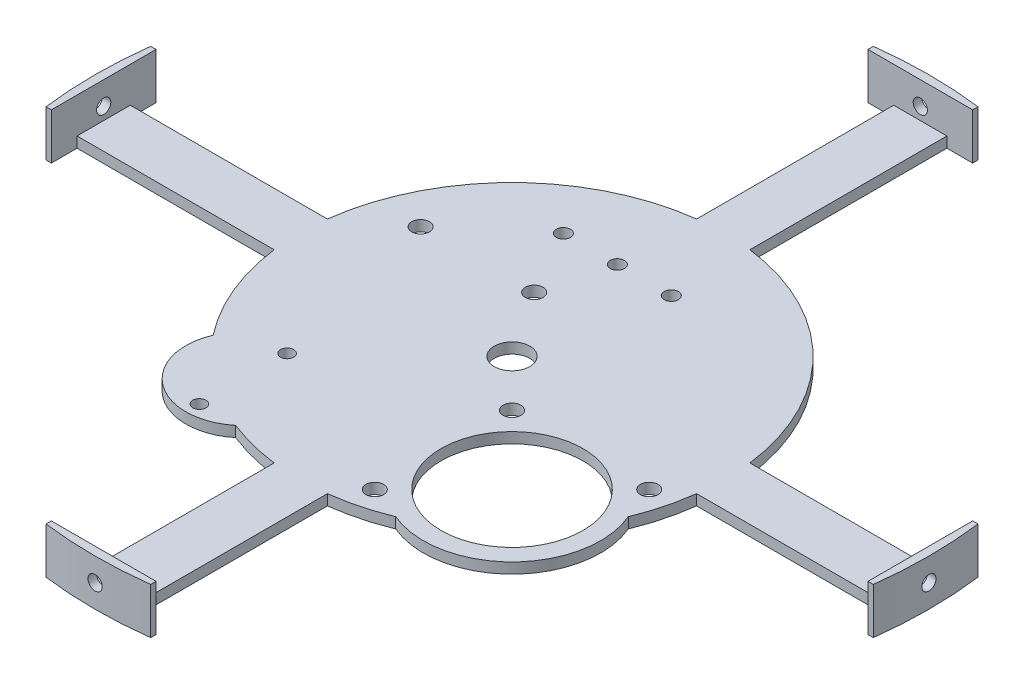
from build123d import *

# Parameters (mm, degrees)
SKETCH1_R                       = 76.2
BOSS_EXTRUDE1_DEPTH             = 3.81
BOSS_EXTRUDE3_DEPTH             = 3.81
SKETCH5_R                       = 6.35
CUT_EXTRUDE1_DEPTH              = 4.81
BOSS_EXTRUDE4_START             = -3.81
BOSS_EXTRUDE4_DEPTH             = 16.51
SKETCH9_R                       = 3.174999999
CUT_EXTRUDE4_DEPTH              = 3.81
SKETCH11_R                      = 31.75
SKETCH11_R_2                    = 25.4
BOSS_EXTRUDE5_DEPTH             = 3.81
SKETCH12_R                      = 25.4
CUT_EXTRUDE5_DEPTH              = 3.81
SKETCH13_R                      = 20.52955
SKETCH13_R_2                    = 2.3622
BOSS_EXTRUDE7_DEPTH             = 3.81
SKETCH14_R                      = 2.3622
CUT_EXTRUDE6_DEPTH              = 3.81
SKETCH15_R                      = 3.175
CUT_EXTRUDE7_DEPTH              = 3.81
TAP_DRILL_FOR_1_4_20_TAP1_D     = 5.1054
TAP_DRILL_FOR_1_4_20_TAP1_DEPTH = 3.087343788
CIRPATTERN1_COUNT               = 4
SKETCH22_R                      = 2.54
CUT_EXTRUDE8_DEPTH              = 17.78


with BuildPart() as part:
    # Sketch1 → Boss-Extrude1 (new body)
    with BuildSketch(Plane(origin=(0, 0, 0), x_dir=(1, 0, 0), z_dir=(0, 1, 0))):
        Circle(SKETCH1_R)
    extrude(amount=BOSS_EXTRUDE1_DEPTH)

    # Sketch3 → Boss-Extrude3 (add)
    with BuildSketch(Plane(origin=(0, 0, 0), x_dir=(-1, 0, 0), z_dir=(0, -1, 0))):
        with BuildLine():
            Line((9.525, -9.525), (148.920700374, -9.525))
            ThreePointArc((148.920700374, -9.525), (149.225, 0), (148.920700374, 9.525))
            Line((148.920700374, 9.525), (9.525, 9.525))
            Line((9.525, 9.525), (9.525, 148.920700374))
            ThreePointArc((9.525, 148.920700374), (0, 149.225), (-9.525, 148.920700374))
            Line((-9.525, 148.920700374), (-9.525, 9.525))
            Line((-9.525, 9.525), (-148.920700374, 9.525))
            ThreePointArc((-148.920700374, 9.525), (-149.225, 0), (-148.920700374, -9.525))
            Line((-148.920700374, -9.525), (-9.525, -9.525))
            Line((-9.525, -9.525), (-9.525, -148.920700374))
            ThreePointArc((-9.525, -148.920700374), (0, -149.225), (9.525, -148.920700374))
            Line((9.525, -148.920700374), (9.525, -9.525))
        make_face()
    extrude(amount=-BOSS_EXTRUDE3_DEPTH)

    # Sketch5 → Cut-Extrude1 (cut, through all)
    with BuildSketch(Plane(origin=(0, 3.81, 0), x_dir=(1, 0, 0), z_dir=(0, 1, 0))):
        Circle(SKETCH5_R)
    extrude(amount=-CUT_EXTRUDE1_DEPTH, mode=Mode.SUBTRACT)

    # Sketch7 → Boss-Extrude4 (add)
    with BuildSketch(Plane(origin=(0, 3.81, 0), x_dir=(1, 0, 0), z_dir=(0, 1, 0)).offset(BOSS_EXTRUDE4_START)):
        with BuildLine():
            Line((18.739703318, 148.043656212), (18.739703318, 146.138656212))
            Line((18.739703318, 146.138656212), (-18.739703318, 146.138656212))
            Line((-18.739703318, 146.138656212), (-18.739703318, 148.043656212))
            ThreePointArc((-18.739703318, 148.043656212), (0, 149.225), (18.739703318, 148.043656212))
        make_face()
    boss_extrude4 = extrude(amount=BOSS_EXTRUDE4_DEPTH)

    # Sketch9 → Cut-Extrude4 (cut)
    with BuildSketch(Plane.XZ):
        with Locations((-56.514999999, -23.8125)):
            Circle(SKETCH9_R)
        with Locations((-15.874999999, -23.8125)):
            Circle(SKETCH9_R)
    extrude(amount=-CUT_EXTRUDE4_DEPTH, mode=Mode.SUBTRACT)

    # Sketch11 → Boss-Extrude5 (add)
    with BuildSketch(Plane(origin=(0, 3.81, 0), x_dir=(1, 0, 0), z_dir=(0, 1, 0))):
        with Locations((41.275, -41.275)):
            Circle(SKETCH11_R)
        with Locations((41.275, -41.275)):
            Circle(SKETCH11_R_2, mode=Mode.SUBTRACT)
    extrude(amount=-BOSS_EXTRUDE5_DEPTH)

    # Sketch12 → Cut-Extrude5 (cut)
    with BuildSketch(Plane(origin=(0, 3.81, 0), x_dir=(1, 0, 0), z_dir=(0, 1, 0))):
        with Locations((41.275, -41.275)):
            Circle(SKETCH12_R)
    extrude(amount=-CUT_EXTRUDE5_DEPTH, mode=Mode.SUBTRACT)

    # Sketch13 → Boss-Extrude7 (add)
    with BuildSketch(Plane(origin=(0, 3.81, 0), x_dir=(1, 0, 0), z_dir=(0, 1, 0))):
        with Locations((-41.16870274, -55.03340443)):
            Circle(SKETCH13_R)
        with Locations((-41.17109409, -70.730891948)):
            Circle(SKETCH13_R_2, mode=Mode.SUBTRACT)
        with Locations((-41.166311391, -39.335916913)):
            Circle(SKETCH13_R_2, mode=Mode.SUBTRACT)
    extrude(amount=-BOSS_EXTRUDE7_DEPTH)

    # Sketch14 → Cut-Extrude6 (cut)
    with BuildSketch(Plane(origin=(0, 3.81, 0), x_dir=(1, 0, 0), z_dir=(0, 1, 0))):
        with Locations((-41.166311391, -39.335916913)):
            Circle(SKETCH14_R)
    extrude(amount=-CUT_EXTRUDE6_DEPTH, mode=Mode.SUBTRACT)

    # Sketch15 → Cut-Extrude7 (cut)
    with BuildSketch(Plane(origin=(0, 3.81, 0), x_dir=(1, 0, 0), z_dir=(0, 1, 0))):
        with Locations((16.720717023, -16.720717023)):
            Circle(SKETCH15_R)
        with Locations((65.829282977, -16.720717023)):
            Circle(SKETCH15_R)
        with Locations((16.720717023, -65.829282977)):
            Circle(SKETCH15_R)
    extrude(amount=-CUT_EXTRUDE7_DEPTH, mode=Mode.SUBTRACT)

    # Tap Drill for 1/4-20 Tap1
    with Locations(Plane(origin=(0, 0, -149.225), x_dir=(-1, 0, 0), z_dir=(0, 0, -1))):
        with Locations((0, 8.255)):
            tap_drill_for_1_4_20_tap1 = Hole(TAP_DRILL_FOR_1_4_20_TAP1_D / 2, depth=TAP_DRILL_FOR_1_4_20_TAP1_DEPTH)

    # CirPattern1: Boss-Extrude4, Tap Drill for 1/4-20 Tap1 ×4 about axis
    cirpattern1_axis = Axis((0, 0, 0), (0, 1, 0))
    for i in range(1, CIRPATTERN1_COUNT):
        add(boss_extrude4.rotate(cirpattern1_axis, i * 360 / CIRPATTERN1_COUNT))
        add(tap_drill_for_1_4_20_tap1.rotate(cirpattern1_axis, i * 360 / CIRPATTERN1_COUNT), mode=Mode.SUBTRACT)

    # Sketch22 → Cut-Extrude8 (cut)
    with BuildSketch(Plane(origin=(0, 3.81, 0), x_dir=(1, 0, 0), z_dir=(0, 1, 0))):
        with Locations((9.676222664, 47.327342728)):
            Circle(SKETCH22_R)
        with Locations((-9.629274443, 47.327342728)):
            Circle(SKETCH22_R)
        with Locations((-28.93477155, 47.327342728)):
            Circle(SKETCH22_R)
    extrude(amount=-CUT_EXTRUDE8_DEPTH, mode=Mode.SUBTRACT)


solid = part.part
